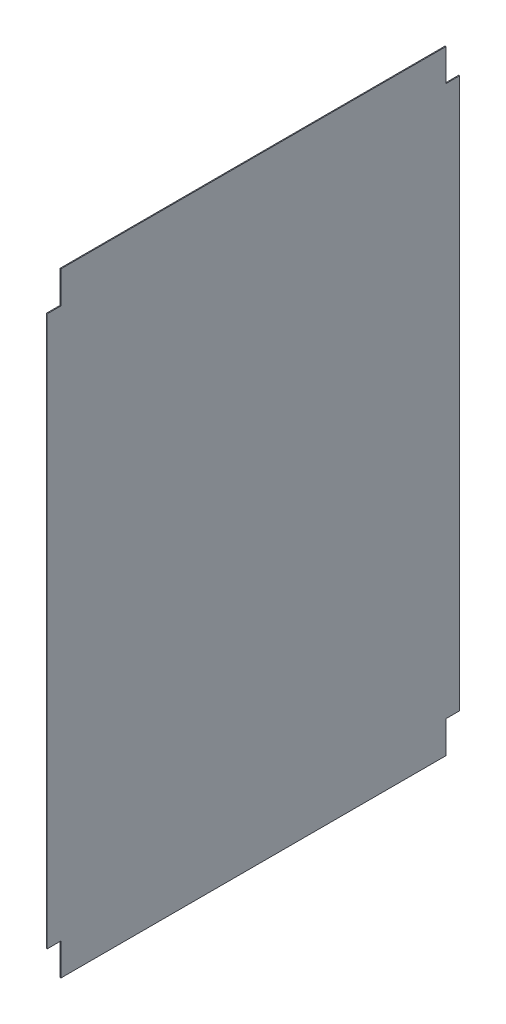
from build123d import *

# Parameters (mm, degrees)
SKETCH1_W           = 45
SKETCH1_H           = 67
BOSS_EXTRUDE1_DEPTH = 0.1
SKETCH3_W           = 1.5
SKETCH3_H           = 3.5
CUT_EXTRUDE1_DEPTH  = 0.1


with BuildPart() as part:
    # Sketch1 → Boss-Extrude1 (new body)
    with BuildSketch(Plane(origin=(0, 0, 0), x_dir=(0, 0, -1), z_dir=(1, 0, 0))):
        with Locations((1.517991004, -15.351574213)):
            Rectangle(SKETCH1_W, SKETCH1_H)
    extrude(amount=BOSS_EXTRUDE1_DEPTH)

    # Sketch3 → Cut-Extrude1 (cut)
    with BuildSketch(Plane(origin=(0.1, 0, 0), x_dir=(0, 0, -1), z_dir=(1, 0, 0))):
        with Locations((-20.232008996, 16.398425787)):
            Rectangle(SKETCH3_W, SKETCH3_H)
        with Locations((23.267991004, 16.398425787)):
            Rectangle(SKETCH3_W, SKETCH3_H)
        with Locations((-20.232008996, -47.101574213)):
            Rectangle(SKETCH3_W, SKETCH3_H)
        with Locations((23.267991004, -47.101574213)):
            Rectangle(SKETCH3_W, SKETCH3_H)
    extrude(amount=-CUT_EXTRUDE1_DEPTH, mode=Mode.SUBTRACT)


solid = part.part
